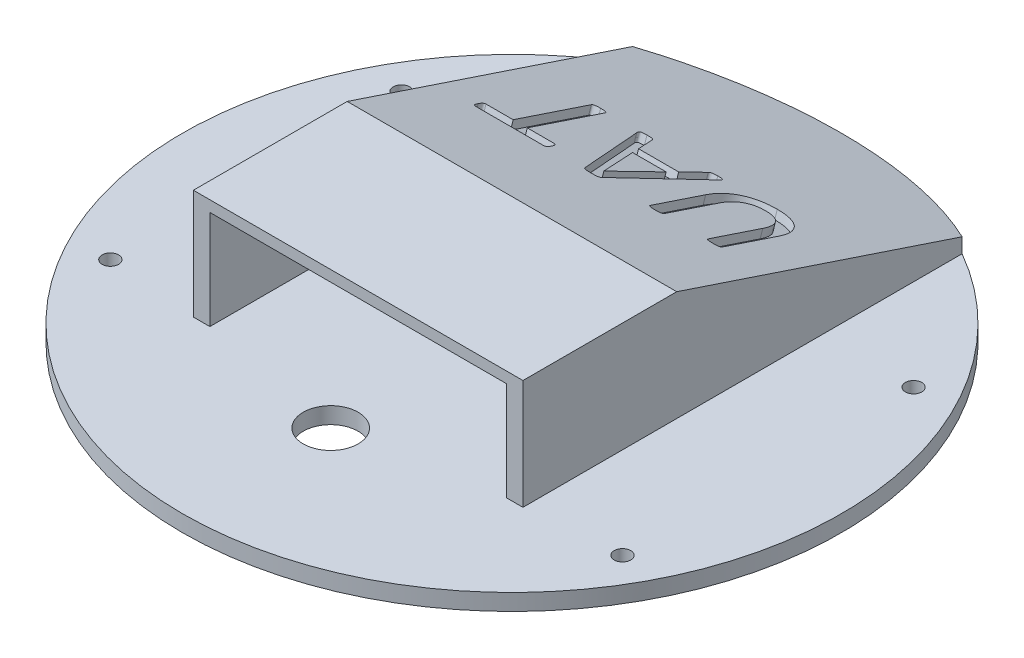
from build123d import *

# Parameters (mm, degrees)
SKETCH1_R               = 60
BOSS_EXTRUDE1_DEPTH     = 3
SKETCH2_R               = 1.5
CUT_EXTRUDE1_DEPTH      = 1
CUT_EXTRUDE1_DEPTH_BACK = 4
BOSS_EXTRUDE2_DEPTH     = 18
SKETCH4_W               = 60
SKETCH4_H               = 28
BOSS_EXTRUDE3_DEPTH     = 2
SKETCH5_R               = 5
CUT_EXTRUDE2_DEPTH      = 21
CUT_EXTRUDE2_DEPTH_BACK = 4
BOSS_EXTRUDE4_DEPTH     = 60
CUT_EXTRUDE3_DEPTH      = 4
CUT_EXTRUDE3_DEPTH_BACK = 21
CUT_EXTRUDE4_DEPTH      = 1.5


with BuildPart() as part:
    # Sketch1 → Boss-Extrude1 (new body)
    with BuildSketch(Plane(origin=(0, 0, 0), x_dir=(1, 0, 0), z_dir=(0, 1, 0))):
        Circle(SKETCH1_R)
    extrude(amount=BOSS_EXTRUDE1_DEPTH)

    # Sketch2 → Cut-Extrude1 (cut, two sides)
    with BuildSketch(Plane(origin=(0, 3, 0), x_dir=(1, 0, 0), z_dir=(0, 1, 0))) as cut_extrude1_sk:
        with Locations((-46.621488653, -26.5)):
            Circle(SKETCH2_R)
        with Locations((-46.621488653, 26.5)):
            Circle(SKETCH2_R)
        with Locations((46.621488653, 26.5)):
            Circle(SKETCH2_R)
        with Locations((46.621488653, -26.5)):
            Circle(SKETCH2_R)
    extrude(amount=CUT_EXTRUDE1_DEPTH, mode=Mode.SUBTRACT)
    extrude(cut_extrude1_sk.sketch, amount=-CUT_EXTRUDE1_DEPTH_BACK, mode=Mode.SUBTRACT)

    # Sketch3 → Boss-Extrude2 (add)
    with BuildSketch(Plane(origin=(0, 3, 0), x_dir=(1, 0, 0), z_dir=(0, 1, 0))):
        Polygon((-27, -28), (-27, -3), (27, -3), (27, -28), (30, -28), (30, 0), (-30, 0), (-30, -28), align=None)
    extrude(amount=BOSS_EXTRUDE2_DEPTH)

    # Sketch4 → Boss-Extrude3 (add)
    with BuildSketch(Plane(origin=(0, 21, 0), x_dir=(1, 0, 0), z_dir=(0, 1, 0))):
        with Locations((0, -14)):
            Rectangle(SKETCH4_W, SKETCH4_H)
    extrude(amount=BOSS_EXTRUDE3_DEPTH)

    # Sketch5 → Cut-Extrude2 (cut, two sides)
    with BuildSketch(Plane(origin=(0, 3, 0), x_dir=(1, 0, 0), z_dir=(0, 1, 0))) as cut_extrude2_sk:
        with Locations((0, -33)):
            Circle(SKETCH5_R)
    extrude(amount=CUT_EXTRUDE2_DEPTH, mode=Mode.SUBTRACT)
    extrude(cut_extrude2_sk.sketch, amount=-CUT_EXTRUDE2_DEPTH_BACK, mode=Mode.SUBTRACT)

    # Sketch6 → Boss-Extrude4 (add)
    with BuildSketch(Plane(origin=(30, 0, 0), x_dir=(0, 0, -1), z_dir=(1, 0, 0))):
        Polygon((0, 23), (60, 3), (0, 3), align=None)
    extrude(amount=-BOSS_EXTRUDE4_DEPTH)

    # Sketch7 → Cut-Extrude3 (cut, two sides)
    with BuildSketch(Plane.XZ.offset(-3)) as cut_extrude3_sk:
        with BuildLine():
            ThreePointArc((0, -60), (-15.529142706, -57.955549577), (-30, -51.961524227))
            Line((-30, -51.961524227), (-30, -60))
            Line((-30, -60), (0, -60))
        make_face()
        with BuildLine():
            ThreePointArc((30, -51.961524227), (15.529142706, -57.955549577), (0, -60))
            Line((0, -60), (30, -60))
            Line((30, -60), (30, -51.961524227))
        make_face()
    extrude(amount=CUT_EXTRUDE3_DEPTH, mode=Mode.SUBTRACT)
    extrude(cut_extrude3_sk.sketch, amount=-CUT_EXTRUDE3_DEPTH_BACK, mode=Mode.SUBTRACT)

    # Sketch8 → Cut-Extrude4 (cut)
    with BuildSketch(Plane(origin=(0, 20.7, -6.9), x_dir=(1, 0, 0), z_dir=(0, 0.948683298, -0.316227766))):
        with BuildLine():
            add(Edge.make_bspline(
                [(8.382352941, 21.065193603), (8.387151635, 21.322818197), (8.396529161, 21.826263794), (8.487069002, 22.558165601), (8.631118564, 23.247393764), (8.831547757, 23.893088243), (9.088574224, 24.494491158), (9.400418957, 25.046415278), (9.754594805, 25.555211854), (10.164022703, 26.01095783), (10.620008866, 26.419740809), (11.124615166, 26.774986286), (11.678019911, 27.073492419), (12.274667302, 27.322406031), (12.91623088, 27.521692418), (13.602882928, 27.653487263), (14.330004396, 27.741827177), (14.829301628, 27.751437207), (15.085592831, 27.756370073)],
                knots=[0, 0, 0, 0, 0.000772572, 0.001509747, 0.0022085, 0.002882566, 0.003534648, 0.004166594, 0.004781302, 0.005390741, 0.006000179, 0.006614887, 0.007237476, 0.007882716, 0.008551749, 0.009248881, 0.009977595, 0.010746148, 0.010746148, 0.010746148, 0.010746148], degree=3))
            add(Edge.make_bspline(
                [(15.085592831, 27.756370073), (15.320447577, 27.752776609), (15.780889796, 27.745731476), (16.45527624, 27.659654942), (17.10013376, 27.536509396), (17.7086703, 27.348294297), (18.282898323, 27.117242067), (18.815063626, 26.830622978), (19.305026164, 26.495612966), (19.749945875, 26.111019867), (20.152627878, 25.677032145), (20.506263195, 25.189745202), (20.809217153, 24.649277032), (21.062407682, 24.060353011), (21.262961482, 23.423204473), (21.408242498, 22.738135068), (21.491875232, 22.005552677), (21.502103837, 21.501032747), (21.507352941, 21.24212375)],
                knots=[0, 0, 0, 0, 0.000704113, 0.001380442, 0.002036566, 0.002671307, 0.003288104, 0.003890805, 0.004480831, 0.005065281, 0.005651458, 0.006253086, 0.006867071, 0.007506482, 0.008172876, 0.008867696, 0.009604399, 0.01038099, 0.01038099, 0.01038099, 0.01038099], degree=3))
            Line((21.507352941, 21.24212375), (21.507352941, 10.429279081))
            add(Edge.make_bspline(
                [(21.507352941, 10.429279081), (21.50400426, 10.395362931), (21.497402291, 10.328496796), (21.450665532, 10.231948279), (21.356914559, 10.157523418), (21.223452093, 10.1028719), (21.046661417, 10.069148024), (20.825722814, 10.022837907), (20.541227305, 10.002921264), (20.330486195, 10.000418046), (20.212545956, 9.999017132)],
                knots=[0, 0, 0, 0, 0.000101807, 0.000200714, 0.000311933, 0.000452386, 0.000629909, 0.000850742, 0.001129248, 0.0014832, 0.0014832, 0.0014832, 0.0014832], degree=3))
            add(Edge.make_bspline(
                [(20.212545956, 9.999017132), (20.101308341, 10.000619543), (19.894604202, 10.003597176), (19.611485752, 10.022962191), (19.385133945, 10.068793841), (19.20767946, 10.101190554), (19.07865832, 10.15835141), (18.990454949, 10.233284797), (18.943675455, 10.32839692), (18.937138987, 10.39532932), (18.933823529, 10.429279081)],
                knots=[0, 0, 0, 0, 0.000333851, 0.00062037, 0.000849116, 0.001026639, 0.001159763, 0.00126796, 0.001366867, 0.001468674, 0.001468674, 0.001468674, 0.001468674], degree=3))
            Line((18.933823529, 10.429279081), (18.933823529, 20.900326875))
            add(Edge.make_bspline(
                [(18.933823529, 20.900326875), (18.931195252, 21.094799583), (18.926091536, 21.472436019), (18.873710767, 22.019619102), (18.785708312, 22.527675042), (18.66547891, 22.997365796), (18.512761712, 23.429665226), (18.32922376, 23.825829277), (18.109593534, 24.181537495), (17.865308977, 24.502025228), (17.587214464, 24.781242045), (17.286449996, 25.029081216), (16.952721937, 25.234941246), (16.594471786, 25.40244451), (16.213961166, 25.537763276), (15.808772776, 25.628025443), (15.380804824, 25.685946034), (15.087128739, 25.693619091), (14.936810662, 25.697546544)],
                knots=[0, 0, 0, 0, 0.000583287, 0.001132655, 0.001646984, 0.002128783, 0.002585372, 0.003020697, 0.003435868, 0.003837218, 0.00422677, 0.004615513, 0.005003818, 0.005399548, 0.005800152, 0.006212764, 0.006642707, 0.007093523, 0.007093523, 0.007093523, 0.007093523], degree=3))
            add(Edge.make_bspline(
                [(14.936810662, 25.697546544), (14.783922882, 25.692942665), (14.485288634, 25.683949951), (14.048980405, 25.635570103), (13.641142437, 25.534902367), (13.257056136, 25.408943582), (12.900920953, 25.242715007), (12.571363051, 25.041047356), (12.272656213, 24.797574811), (12.003332929, 24.518159305), (11.757688865, 24.206767798), (11.551283122, 23.854136333), (11.369232963, 23.469501154), (11.215105552, 23.050441482), (11.101109335, 22.594368022), (11.016483638, 22.102524663), (10.963531755, 21.574356565), (10.958477982, 21.208741677), (10.955882353, 21.020961066)],
                knots=[0, 0, 0, 0, 0.000458851, 0.000896269, 0.001313712, 0.00171681, 0.002107192, 0.002489962, 0.002873048, 0.003259789, 0.003652319, 0.004059885, 0.004482583, 0.004927823, 0.005396937, 0.005890768, 0.006424126, 0.006987316, 0.006987316, 0.006987316, 0.006987316], degree=3))
            Line((10.955882353, 21.020961066), (10.955882353, 10.429279081))
            add(Edge.make_bspline(
                [(10.955882353, 10.429279081), (10.952533715, 10.3953627), (10.94593183, 10.328496111), (10.899194425, 10.231951066), (10.805446438, 10.157510153), (10.671968256, 10.102943127), (10.492666151, 10.068268255), (10.268712739, 10.023784225), (9.984440874, 10.002847095), (9.776351618, 10.000382472), (9.661075368, 9.999017132)],
                knots=[0, 0, 0, 0, 0.000101807, 0.000200714, 0.000311933, 0.000452386, 0.000629909, 0.000858655, 0.00113716, 0.001483072, 0.001483072, 0.001483072, 0.001483072], degree=3))
            add(Edge.make_bspline(
                [(9.661075368, 9.999017132), (9.54983583, 10.000529056), (9.34579802, 10.003302259), (9.066695013, 10.023221221), (8.845743987, 10.068697427), (8.670828122, 10.101313012), (8.542155361, 10.16062075), (8.448698378, 10.232599487), (8.390592752, 10.326285177), (8.385091041, 10.39505407), (8.382352941, 10.429279081)],
                knots=[0, 0, 0, 0, 0.000333851, 0.000612357, 0.000837146, 0.001010755, 0.001143878, 0.00125818, 0.001360936, 0.001462743, 0.001462743, 0.001462743, 0.001462743], degree=3))
            Line((8.382352941, 10.429279081), (8.382352941, 21.065193603))
        make_face()
        with BuildLine():
            add(Edge.make_bspline(
                [(-9.419232537, 26.602302978), (-9.449985043, 26.690042916), (-9.504097864, 26.844432142), (-9.543947621, 27.059031884), (-9.527722614, 27.234769826), (-9.432060751, 27.365805839), (-9.272779696, 27.446558555), (-9.047646826, 27.476440679), (-8.752159398, 27.494874751), (-8.527962327, 27.497526123), (-8.401884191, 27.499017132)],
                knots=[0, 0, 0, 0, 0.000278506, 0.000490065, 0.00065271, 0.000791075, 0.000956675, 0.001173556, 0.001467787, 0.00184586, 0.00184586, 0.00184586, 0.00184586], degree=3))
            add(Edge.make_bspline(
                [(-8.401884191, 27.499017132), (-8.275854468, 27.498815356), (-8.051809324, 27.498456656), (-7.753862199, 27.483602612), (-7.527143973, 27.457929096), (-7.360943033, 27.418520394), (-7.236647714, 27.36828567), (-7.156105385, 27.287419351), (-7.093355595, 27.193414575), (-7.060495638, 27.122928556), (-7.042738971, 27.084839742)],
                knots=[0, 0, 0, 0, 0.000378009, 0.000671992, 0.000894939, 0.001060735, 0.00118487, 0.001290113, 0.001397184, 0.001523066, 0.001523066, 0.001523066, 0.001523066], degree=3))
            Line((-7.042738971, 27.084839742), (-5.538832721, 22.866664191))
            Line((-5.538832721, 22.866664191), (1.763556985, 22.866664191))
            Line((1.763556985, 22.866664191), (3.203125, 27.028543787))
            add(Edge.make_bspline(
                [(3.203125, 27.028543787), (3.21816773, 27.066504315), (3.247186011, 27.139732332), (3.307894956, 27.241930111), (3.397788499, 27.324415659), (3.516336598, 27.396657821), (3.679695616, 27.447464655), (3.89524661, 27.475293755), (4.170520525, 27.494970279), (4.375908166, 27.497572827), (4.489889706, 27.499017132)],
                knots=[0, 0, 0, 0, 0.000122496, 0.000236302, 0.000352915, 0.000484635, 0.000649942, 0.000861501, 0.001135677, 0.001477569, 0.001477569, 0.001477569, 0.001477569], degree=3))
            add(Edge.make_bspline(
                [(4.489889706, 27.499017132), (4.609280047, 27.498369159), (4.824351993, 27.497201889), (5.11234745, 27.469015785), (5.331520856, 27.430499706), (5.49012614, 27.352878132), (5.579569358, 27.221348558), (5.590210749, 27.04686147), (5.552461221, 26.832340943), (5.497985435, 26.677969431), (5.467026654, 26.590239559)],
                knots=[0, 0, 0, 0, 0.000357972, 0.000644857, 0.000867295, 0.001023913, 0.00115998, 0.001322078, 0.001533637, 0.001812143, 0.001812143, 0.001812143, 0.001812143], degree=3))
            Line((5.467026654, 26.590239559), (-0.419921875, 10.465469338))
            add(Edge.make_bspline(
                [(-0.419921875, 10.465469338), (-0.439794101, 10.421778309), (-0.477886297, 10.338028895), (-0.560490348, 10.226366864), (-0.678619951, 10.142705428), (-0.831312076, 10.077340891), (-1.030083096, 10.04305212), (-1.275611352, 10.014353547), (-1.58055351, 9.999954643), (-1.80453416, 9.999350016), (-1.927849265, 9.999017132)],
                knots=[0, 0, 0, 0, 0.000143865, 0.000275768, 0.000410881, 0.000572978, 0.000770137, 0.001013042, 0.001315056, 0.001685022, 0.001685022, 0.001685022, 0.001685022], degree=3))
            add(Edge.make_bspline(
                [(-1.927849265, 9.999017132), (-2.060559532, 9.999263626), (-2.30063891, 9.999709545), (-2.62684908, 10.014916047), (-2.889101299, 10.041480055), (-3.097760091, 10.081169109), (-3.259028082, 10.147286458), (-3.383086591, 10.233339107), (-3.470660871, 10.349127069), (-3.508621436, 10.436398301), (-3.528262868, 10.481553897)],
                knots=[0, 0, 0, 0, 0.000398113, 0.000720206, 0.000979094, 0.001188888, 0.001354684, 0.001498661, 0.001636205, 0.001783677, 0.001783677, 0.001783677, 0.001783677], degree=3))
            Line((-3.528262868, 10.481553897), (-9.419232537, 26.602302978))
        make_face()
        Polygon((-1.85948989, 12.315193603), (-1.847426471, 12.315193603), (1.180491728, 21.065193603), (-4.927619485, 21.065193603), align=None, mode=Mode.SUBTRACT)
        with BuildLine():
            add(Edge.make_bspline(
                [(-23.529411765, 11.044513456), (-23.527677935, 11.127647588), (-23.524456154, 11.282126428), (-23.506348462, 11.496353777), (-23.471590615, 11.675007086), (-23.421387302, 11.819246406), (-23.351990648, 11.928336108), (-23.268530026, 12.004165214), (-23.172322613, 12.053350519), (-23.102400251, 12.056330922), (-23.066980699, 12.057840662)],
                knots=[0, 0, 0, 0, 0.00024944, 0.000463507, 0.000644101, 0.000794235, 0.00091915, 0.001027347, 0.001129867, 0.00123511, 0.00123511, 0.00123511, 0.00123511], degree=3))
            Line((-23.066980699, 12.057840662), (-18.125, 12.057840662))
            Line((-18.125, 12.057840662), (-18.125, 27.072776323))
            add(Edge.make_bspline(
                [(-18.125, 27.072776323), (-18.121896041, 27.106823034), (-18.115885683, 27.17274945), (-18.066763799, 27.26641822), (-17.976501179, 27.340381874), (-17.84236212, 27.389452573), (-17.668424352, 27.432665168), (-17.44230877, 27.467284655), (-17.160688857, 27.497396805), (-16.952280945, 27.498444053), (-16.838235294, 27.499017132)],
                knots=[0, 0, 0, 0, 0.000101807, 0.000197134, 0.000308354, 0.000443526, 0.000622003, 0.000846107, 0.001128991, 0.001470882, 0.001470882, 0.001470882, 0.001470882], degree=3))
            add(Edge.make_bspline(
                [(-16.838235294, 27.499017132), (-16.726850178, 27.498501807), (-16.522419521, 27.497556006), (-16.242431466, 27.466082051), (-16.013168571, 27.433373835), (-15.834769325, 27.388558053), (-15.696875335, 27.342856237), (-15.609693309, 27.264922794), (-15.560465309, 27.172897105), (-15.554533818, 27.106873319), (-15.551470588, 27.072776323)],
                knots=[0, 0, 0, 0, 0.000333851, 0.000612734, 0.000844779, 0.001027154, 0.001166044, 0.001274241, 0.001369569, 0.001471376, 0.001471376, 0.001471376, 0.001471376], degree=3))
            Line((-15.551470588, 27.072776323), (-15.551470588, 12.057840662))
            Line((-15.551470588, 12.057840662), (-10.60948989, 12.057840662))
            add(Edge.make_bspline(
                [(-10.60948989, 12.057840662), (-10.574031562, 12.056354838), (-10.504032652, 12.053421649), (-10.408398259, 12.003882912), (-10.323613642, 11.930468552), (-10.265326254, 11.816313303), (-10.211529348, 11.675626916), (-10.180769204, 11.495595551), (-10.148651952, 11.282860459), (-10.147615508, 11.127798742), (-10.147058824, 11.044513456)],
                knots=[0, 0, 0, 0, 0.000105243, 0.000207763, 0.00031596, 0.000436662, 0.000586796, 0.00076739, 0.000982361, 0.001231801, 0.001231801, 0.001231801, 0.001231801], degree=3))
            add(Edge.make_bspline(
                [(-10.147058824, 11.044513456), (-10.147710579, 10.95991256), (-10.148935629, 10.800895444), (-10.180658496, 10.58128852), (-10.212269325, 10.393851166), (-10.263641901, 10.244411714), (-10.327084279, 10.128501079), (-10.411202995, 10.051672197), (-10.510712704, 10.008926029), (-10.580935816, 10.002411921), (-10.617532169, 9.999017132)],
                knots=[0, 0, 0, 0, 0.000253459, 0.000476406, 0.000664886, 0.000822584, 0.000948786, 0.001056984, 0.001157834, 0.00126759, 0.00126759, 0.00126759, 0.00126759], degree=3))
            Line((-10.617532169, 9.999017132), (-23.058938419, 9.999017132))
            add(Edge.make_bspline(
                [(-23.058938419, 9.999017132), (-23.094046297, 10.002796064), (-23.163853809, 10.010309985), (-23.264937469, 10.05011621), (-23.348580372, 10.130773387), (-23.423105974, 10.241358129), (-23.47084653, 10.394494938), (-23.506481065, 10.580541485), (-23.524250382, 10.801597551), (-23.527617234, 10.960055472), (-23.529411765, 11.044513456)],
                knots=[0, 0, 0, 0, 0.00010578, 0.000210329, 0.000318527, 0.000449013, 0.000606711, 0.000795191, 0.001017266, 0.001270725, 0.001270725, 0.001270725, 0.001270725], degree=3))
        make_face()
    extrude(amount=-CUT_EXTRUDE4_DEPTH, mode=Mode.SUBTRACT)


solid = part.part
